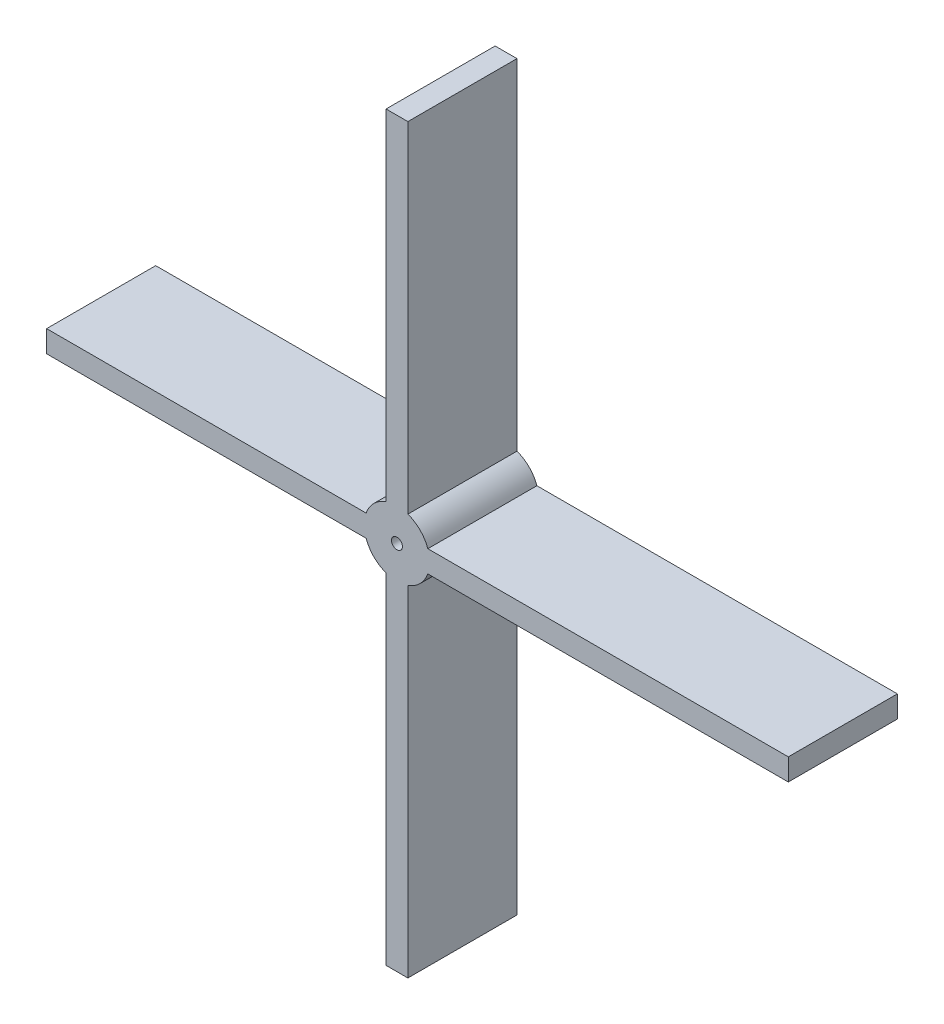
from build123d import *

# Parameters (mm, degrees)
BOSS_EXTRUDE2_DEPTH      = 50
SKETCH2_R                = 15
BOSS_EXTRUDE3_DEPTH      = 50
F_5_0_5_DIAMETER_HOLE1_D = 5


with BuildPart() as part:
    # Sketch1 → Boss-Extrude2 (new body)
    with BuildSketch(Plane.XY):
        Polygon((-160.605737387, 5), (-5, 5), (-5, 170), (5, 170), (5, 5), (179.394262613, 5), (179.394262613, -5), (5, -5), (5, -170), (-5, -170), (-5, -5), (-160.605737387, -5), align=None)
    extrude(amount=BOSS_EXTRUDE2_DEPTH)

    # Sketch2 → Boss-Extrude3 (add)
    with BuildSketch(Plane(origin=(0, 0, 0), x_dir=(-1, 0, 0), z_dir=(0, 0, -1))):
        Circle(SKETCH2_R)
    extrude(amount=-BOSS_EXTRUDE3_DEPTH)

    # Ø5.0 (5) Diameter Hole1 (through all)
    with Locations(Plane.XY.offset(50)):
        with Locations((0, 0)):
            Hole(F_5_0_5_DIAMETER_HOLE1_D / 2)


solid = part.part
